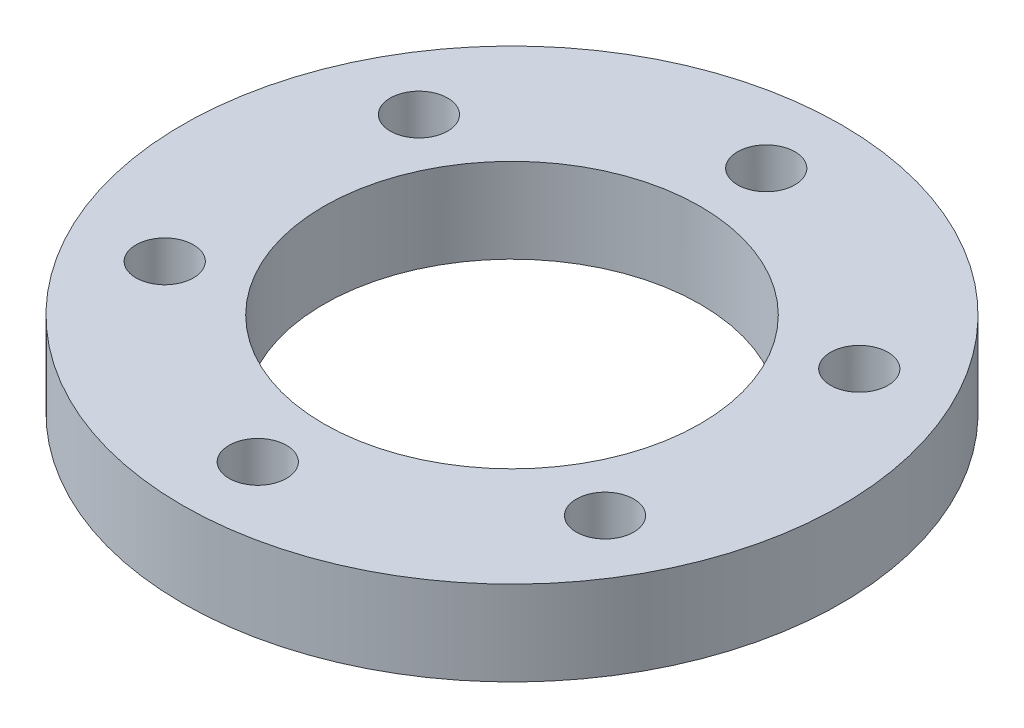
from build123d import *

# Parameters (mm, degrees)
SKETCH_1_R               = 31.5
SKETCH_1_R_2             = 22.5
EXTRUDE_1_DEPTH          = 4.5
SKETCH_2_R               = 2.025
CUT_EXTRUDE_1_DEPTH      = 1
CUT_EXTRUDE_1_DEPTH_BACK = 5.5
SKETCH_3_R               = 22.5
EXTRUDE_2_DEPTH          = 4.5
SKETCH_4_R               = 1.525
CUT_EXTRUDE_2_DEPTH      = 4.5
SKETCH_5_R               = 10
CUT_EXTRUDE_3_DEPTH      = 4.5
SKETCH_6_R               = 31.5
SKETCH_6_R_2             = 17.5
CUT_EXTRUDE_4_DEPTH      = 5.5


with BuildPart() as part:
    # 草图1 → 凸台-拉伸1 (new body)
    with BuildSketch(Plane(origin=(0, 0, 0), x_dir=(1, 0, 0), z_dir=(0, 1, 0))):
        Circle(SKETCH_1_R)
        Circle(SKETCH_1_R_2, mode=Mode.SUBTRACT)
    extrude(amount=EXTRUDE_1_DEPTH)

    # 草图2 → 切除-拉伸1 (cut, two sides)
    with BuildSketch(Plane(origin=(0, 4.5, 0), x_dir=(1, 0, 0), z_dir=(0, 1, 0))) as cut_extrude_1_sk:
        with Locations((0, 26.25)):
            Circle(SKETCH_2_R)
        with Locations((18.561553006, 18.561553006)):
            Circle(SKETCH_2_R)
        with Locations((26.25, 0)):
            Circle(SKETCH_2_R)
        with Locations((18.561553006, -18.561553006)):
            Circle(SKETCH_2_R)
        with Locations((0, -26.25)):
            Circle(SKETCH_2_R)
        with Locations((-18.561553006, -18.561553006)):
            Circle(SKETCH_2_R)
        with Locations((-26.25, 0)):
            Circle(SKETCH_2_R)
        with Locations((-18.561553006, 18.561553006)):
            Circle(SKETCH_2_R)
    extrude(amount=CUT_EXTRUDE_1_DEPTH, mode=Mode.SUBTRACT)
    extrude(cut_extrude_1_sk.sketch, amount=-CUT_EXTRUDE_1_DEPTH_BACK, mode=Mode.SUBTRACT)

    # 草图3 → 凸台-拉伸2 (add)
    with BuildSketch(Plane(origin=(0, 4.5, 0), x_dir=(1, 0, 0), z_dir=(0, 1, 0))):
        Circle(SKETCH_3_R)
    extrude(amount=-EXTRUDE_2_DEPTH)

    # 草图4 → 切除-拉伸2 (cut)
    with BuildSketch(Plane.XZ):
        with Locations((0, 13.5)):
            Circle(SKETCH_4_R)
        with Locations((11.691342951, 6.75)):
            Circle(SKETCH_4_R)
        with Locations((11.691342951, -6.75)):
            Circle(SKETCH_4_R)
        with Locations((0, -13.5)):
            Circle(SKETCH_4_R)
        with Locations((-11.691342951, -6.75)):
            Circle(SKETCH_4_R)
        with Locations((-11.691342951, 6.75)):
            Circle(SKETCH_4_R)
    extrude(amount=-CUT_EXTRUDE_2_DEPTH, mode=Mode.SUBTRACT)

    # 草图5 → 切除-拉伸3 (cut)
    with BuildSketch(Plane.XZ):
        Circle(SKETCH_5_R)
    extrude(amount=-CUT_EXTRUDE_3_DEPTH, mode=Mode.SUBTRACT)

    # 草图6 → 切除-拉伸4 (cut, through all)
    with BuildSketch(Plane.XZ):
        Circle(SKETCH_6_R)
        Circle(SKETCH_6_R_2, mode=Mode.SUBTRACT)
    extrude(amount=-CUT_EXTRUDE_4_DEPTH, mode=Mode.SUBTRACT)


solid = part.part
